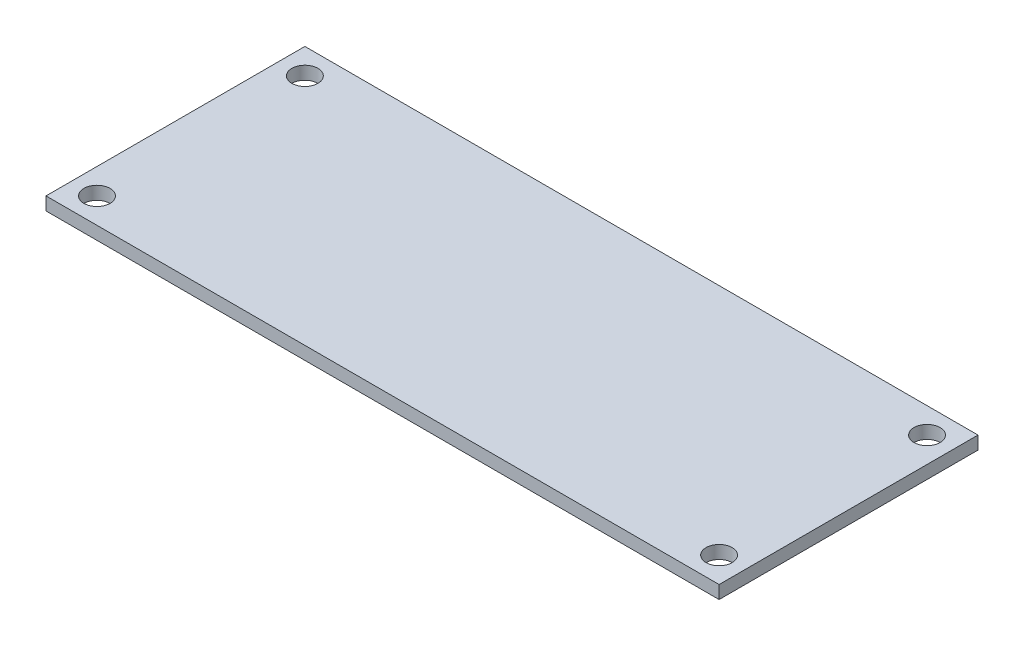
from build123d import *

# Parameters (mm, degrees)
SKETCH1_W           = 82.55
SKETCH1_H           = 31.75
SKETCH1_R           = 1.6
BOSS_EXTRUDE1_DEPTH = 0.8


with BuildPart() as part:
    # Sketch1 → Boss-Extrude1 (new body, symmetric)
    with BuildSketch(Plane(origin=(0, 0, 0), x_dir=(1, 0, 0), z_dir=(0, 1, 0))):
        Rectangle(SKETCH1_W, SKETCH1_H)
        with Locations((-38.15, 12.75)):
            Circle(SKETCH1_R, mode=Mode.SUBTRACT)
        with Locations((38.15, 12.75)):
            Circle(SKETCH1_R, mode=Mode.SUBTRACT)
        with Locations((38.15, -12.75)):
            Circle(SKETCH1_R, mode=Mode.SUBTRACT)
        with Locations((-38.15, -12.75)):
            Circle(SKETCH1_R, mode=Mode.SUBTRACT)
    extrude(amount=BOSS_EXTRUDE1_DEPTH, both=True)


solid = part.part
